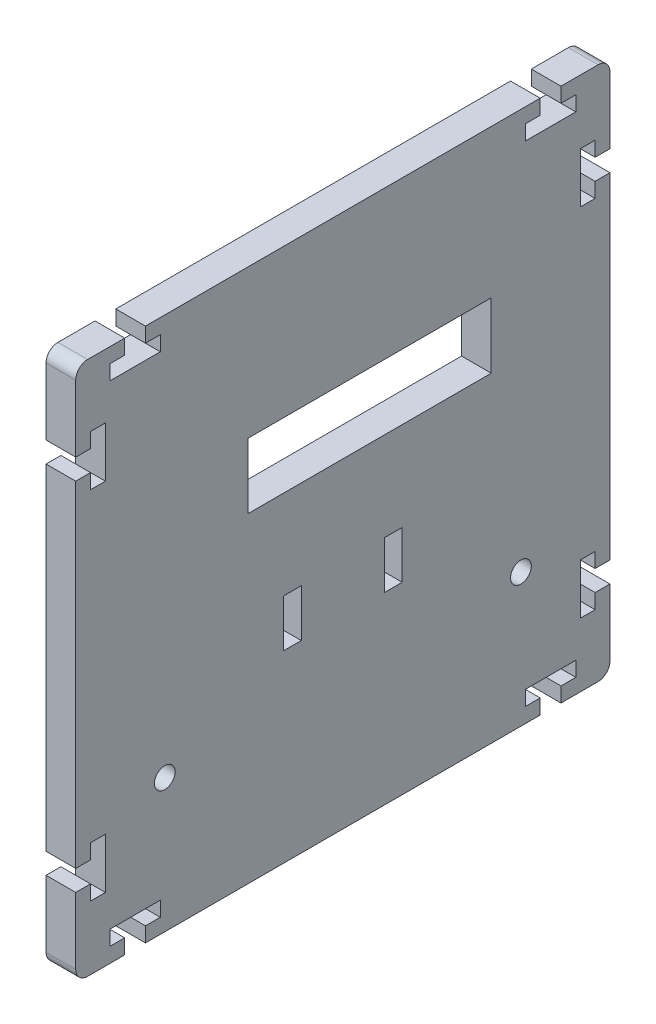
from build123d import *

# Parameters (mm, degrees)
SKETCH_1_R      = 1.75
SKETCH_1_W      = 3
SKETCH_1_H      = 8
SKETCH_1_W_2    = 41
SKETCH_1_H_2    = 11
EXTRUDE_1_DEPTH = 5


with BuildPart() as part:
    # Эскиз1 → Бобышка-Вытянуть1 (new body)
    with BuildSketch(Plane(origin=(0, 0, 0), x_dir=(0, 0, -1), z_dir=(1, 0, 0))):
        with BuildLine():
            Line((-36.75, 45), (-36.75, 42.5))
            Line((-36.75, 42.5), (-39.25, 42.5))
            Line((-39.25, 42.5), (-39.25, 40))
            Line((-39.25, 40), (-30.75, 40))
            Line((-30.75, 40), (-30.75, 42.5))
            Line((-30.75, 42.5), (-33.25, 42.5))
            Line((-33.25, 42.5), (-33.25, 45))
            Line((-33.25, 45), (33.25, 45))
            Line((33.25, 45), (33.25, 42.5))
            Line((33.25, 42.5), (30.75, 42.5))
            Line((30.75, 42.5), (30.75, 40))
            Line((30.75, 40), (39.25, 40))
            Line((39.25, 40), (39.25, 42.5))
            Line((39.25, 42.5), (36.75, 42.5))
            Line((36.75, 42.5), (36.75, 45))
            Line((36.75, 45), (43, 45))
            ThreePointArc((43, 45), (44.414213562, 44.414213562), (45, 43))
            Line((45, 43), (45, 31.75))
            Line((45, 31.75), (42.5, 31.75))
            Line((42.5, 31.75), (42.5, 34.25))
            Line((42.5, 34.25), (40, 34.25))
            Line((40, 34.25), (40, 25.75))
            Line((40, 25.75), (42.5, 25.75))
            Line((42.5, 25.75), (42.5, 28.25))
            Line((42.5, 28.25), (45, 28.25))
            Line((45, 28.25), (45, -28.25))
            Line((45, -28.25), (42.5, -28.25))
            Line((42.5, -28.25), (42.5, -25.75))
            Line((42.5, -25.75), (40, -25.75))
            Line((40, -25.75), (40, -34.25))
            Line((40, -34.25), (42.5, -34.25))
            Line((42.5, -34.25), (42.5, -31.75))
            Line((42.5, -31.75), (45, -31.75))
            Line((45, -31.75), (45, -43))
            ThreePointArc((45, -43), (44.414213562, -44.414213562), (43, -45))
            Line((43, -45), (36.75, -45))
            Line((36.75, -45), (36.75, -42.5))
            Line((36.75, -42.5), (39.25, -42.5))
            Line((39.25, -42.5), (39.25, -40))
            Line((39.25, -40), (30.75, -40))
            Line((30.75, -40), (30.75, -42.5))
            Line((30.75, -42.5), (33.25, -42.5))
            Line((33.25, -42.5), (33.25, -45))
            Line((33.25, -45), (-33.25, -45))
            Line((-33.25, -45), (-33.25, -42.5))
            Line((-33.25, -42.5), (-30.75, -42.5))
            Line((-30.75, -42.5), (-30.75, -40))
            Line((-30.75, -40), (-39.25, -40))
            Line((-39.25, -40), (-39.25, -42.5))
            Line((-39.25, -42.5), (-36.75, -42.5))
            Line((-36.75, -42.5), (-36.75, -45))
            Line((-36.75, -45), (-43, -45))
            ThreePointArc((-43, -45), (-44.414213562, -44.414213562), (-45, -43))
            Line((-45, -43), (-45, -31.75))
            Line((-45, -31.75), (-42.5, -31.75))
            Line((-42.5, -31.75), (-42.5, -34.25))
            Line((-42.5, -34.25), (-40, -34.25))
            Line((-40, -34.25), (-40, -25.75))
            Line((-40, -25.75), (-42.5, -25.75))
            Line((-42.5, -25.75), (-42.5, -28.25))
            Line((-42.5, -28.25), (-45, -28.25))
            Line((-45, -28.25), (-45, 28.25))
            Line((-45, 28.25), (-42.5, 28.25))
            Line((-42.5, 28.25), (-42.5, 25.75))
            Line((-42.5, 25.75), (-40, 25.75))
            Line((-40, 25.75), (-40, 34.25))
            Line((-40, 34.25), (-42.5, 34.25))
            Line((-42.5, 34.25), (-42.5, 31.75))
            Line((-42.5, 31.75), (-45, 31.75))
            Line((-45, 31.75), (-45, 43))
            ThreePointArc((-45, 43), (-44.414213562, 44.414213562), (-43, 45))
            Line((-43, 45), (-36.75, 45))
        make_face()
        with Locations((-30, -22.5)):
            Circle(SKETCH_1_R, mode=Mode.SUBTRACT)
        with Locations((30, -22.5)):
            Circle(SKETCH_1_R, mode=Mode.SUBTRACT)
        with Locations((8.5, -10)):
            Rectangle(SKETCH_1_W, SKETCH_1_H, mode=Mode.SUBTRACT)
        with Locations((-8.5, -10)):
            Rectangle(SKETCH_1_W, SKETCH_1_H, mode=Mode.SUBTRACT)
        with Locations((4.5, 14.5)):
            Rectangle(SKETCH_1_W_2, SKETCH_1_H_2, mode=Mode.SUBTRACT)
    extrude(amount=EXTRUDE_1_DEPTH)


solid = part.part
